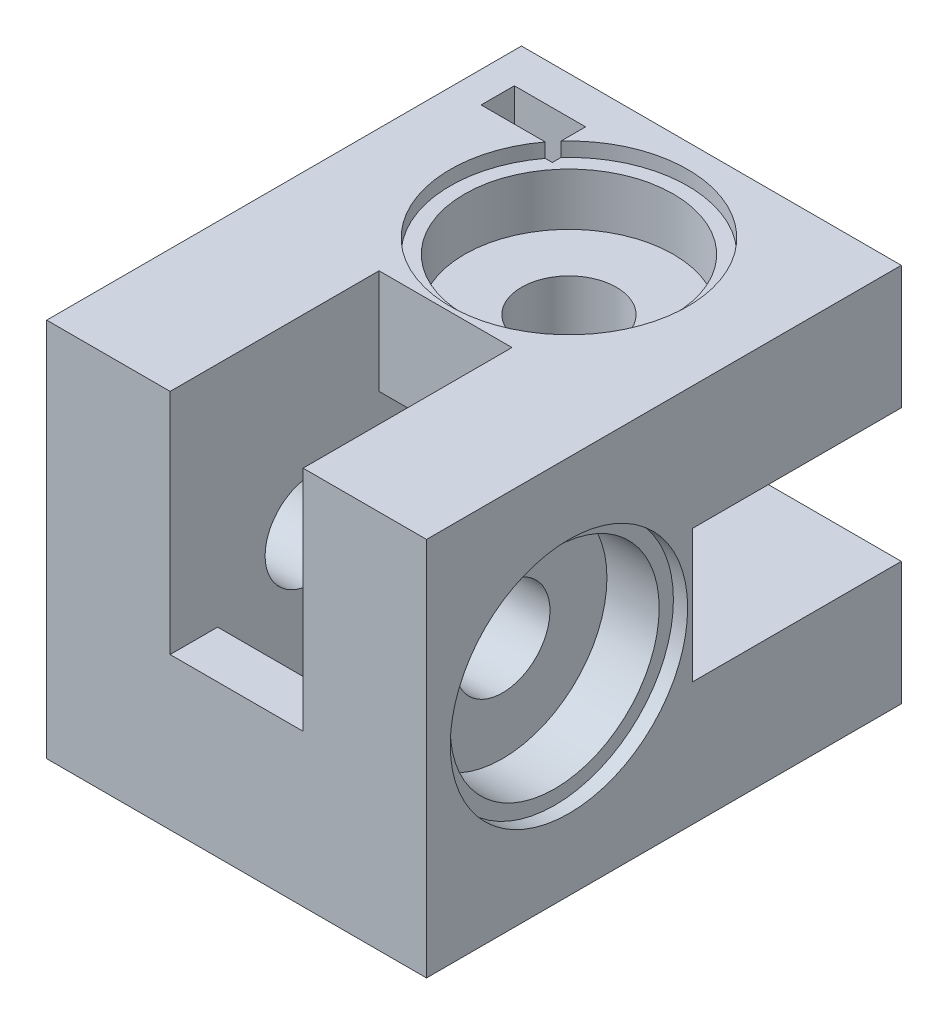
from build123d import *

# Parameters (mm, degrees)
ESQUISSE1_W              = 40
ESQUISSE1_H              = 40
BOSS_EXTRU_1_DEPTH       = 50
ESQUISSE2_R              = 5
ENL_V_MAT_EXTRU_1_DEPTH  = 41
ESQUISSE3_R              = 5
ENL_V_MAT_EXTRU_2_DEPTH  = 41
ESQUISSE4_W              = 20
ESQUISSE4_H              = 14
ENL_V_MAT_EXTRU_3_DEPTH  = 29
ESQUISSE5_W              = 14
ESQUISSE5_H              = 20
ENL_V_MAT_EXTRU_4_DEPTH  = 29
ESQUISSE6_W              = 22
ESQUISSE6_H              = 14
ENL_V_MAT_EXTRU_5_DEPTH  = 24
ESQUISSE7_W              = 14
ESQUISSE7_H              = 22
ENL_V_MAT_EXTRU_6_DEPTH  = 24
ESQUISSE8_R              = 11
ENL_V_MAT_EXTRU_7_DEPTH  = 7
ESQUISSE9_R              = 12.5
ENL_V_MAT_EXTRU_8_DEPTH  = 1.5
ESQUISSE10_R             = 11
ENL_V_MAT_EXTRU_9_DEPTH  = 7
ESQUISSE11_R             = 12.5
ENL_V_MAT_EXTRU_10_DEPTH = 1.5
ESQUISSE13_R             = 2.2
ENL_V_MAT_EXTRU_11_DEPTH = 10
ESQUISSE15_W             = 7.5
ESQUISSE15_H             = 3.5
ENL_V_MAT_EXTRU_13_DEPTH = 12
ESQUISSE16_W             = 7.5
ESQUISSE16_H             = 3.5
ENL_V_MAT_EXTRU_14_DEPTH = 12


with BuildPart() as part:
    # Esquisse1 → Boss.-Extru.1 (new body)
    with BuildSketch(Plane.XY):
        with Locations((-20, 20)):
            Rectangle(ESQUISSE1_W, ESQUISSE1_H)
    extrude(amount=BOSS_EXTRU_1_DEPTH)

    # Esquisse2 → Enlèv. mat.-Extru.1 (cut, through all)
    with BuildSketch(Plane(origin=(0, 40, 0), x_dir=(1, 0, 0), z_dir=(0, 1, 0))):
        with Locations(Location((-20, -15, 0), (0, 0, 270))):  # turned: the seam where the file's is
            Circle(ESQUISSE2_R)
    extrude(amount=-ENL_V_MAT_EXTRU_1_DEPTH, mode=Mode.SUBTRACT)

    # Esquisse3 → Enlèv. mat.-Extru.2 (cut, through all)
    with BuildSketch(Plane.ZY.offset(40)):
        with Locations((35, 20)):
            Circle(ESQUISSE3_R)
    extrude(amount=-ENL_V_MAT_EXTRU_2_DEPTH, mode=Mode.SUBTRACT)

    # Esquisse4 → Enlèv. mat.-Extru.3 (cut)
    with BuildSketch(Plane.ZY.offset(40)):
        with Locations((15, 20)):
            Rectangle(ESQUISSE4_W, ESQUISSE4_H)
    extrude(amount=-ENL_V_MAT_EXTRU_3_DEPTH, mode=Mode.SUBTRACT)

    # Esquisse5 → Enlèv. mat.-Extru.4 (cut)
    with BuildSketch(Plane.XZ):
        with Locations((-20, 35)):
            Rectangle(ESQUISSE5_W, ESQUISSE5_H)
    extrude(amount=-ENL_V_MAT_EXTRU_4_DEPTH, mode=Mode.SUBTRACT)

    # Esquisse6 → Enlèv. mat.-Extru.5 (cut)
    with BuildSketch(Plane(origin=(0, 0, 0), x_dir=(0, 0, -1), z_dir=(1, 0, 0))):
        with Locations((-11, 20)):
            Rectangle(ESQUISSE6_W, ESQUISSE6_H)
    extrude(amount=-ENL_V_MAT_EXTRU_5_DEPTH, mode=Mode.SUBTRACT)

    # Esquisse7 → Enlèv. mat.-Extru.6 (cut)
    with BuildSketch(Plane(origin=(0, 40, 0), x_dir=(1, 0, 0), z_dir=(0, 1, 0))):
        with Locations((-20, -39)):
            Rectangle(ESQUISSE7_W, ESQUISSE7_H)
    extrude(amount=-ENL_V_MAT_EXTRU_6_DEPTH, mode=Mode.SUBTRACT)

    # Esquisse8 → Enlèv. mat.-Extru.7 (cut)
    with BuildSketch(Plane(origin=(0, 0, 0), x_dir=(0, 0, -1), z_dir=(1, 0, 0))):
        with Locations(Location((-35, 20, 0), (0, 0, 90))):  # turned: the seam where the file's is
            Circle(ESQUISSE8_R)
    extrude(amount=-ENL_V_MAT_EXTRU_7_DEPTH, mode=Mode.SUBTRACT)

    # Esquisse9 → Enlèv. mat.-Extru.8 (cut)
    with BuildSketch(Plane(origin=(0, 0, 0), x_dir=(0, 0, -1), z_dir=(1, 0, 0))):
        with Locations(Location((-35, 20, 0), (0, 0, 90))):  # turned: the seam where the file's is
            Circle(ESQUISSE9_R)
    extrude(amount=-ENL_V_MAT_EXTRU_8_DEPTH, mode=Mode.SUBTRACT)

    # Esquisse10 → Enlèv. mat.-Extru.9 (cut)
    with BuildSketch(Plane(origin=(0, 40, 0), x_dir=(1, 0, 0), z_dir=(0, 1, 0))):
        with Locations(Location((-20, -15, 0), (0, 0, 270))):  # turned: the seam where the file's is
            Circle(ESQUISSE10_R)
    extrude(amount=-ENL_V_MAT_EXTRU_9_DEPTH, mode=Mode.SUBTRACT)

    # Esquisse11 → Enlèv. mat.-Extru.10 (cut)
    with BuildSketch(Plane(origin=(0, 40, 0), x_dir=(1, 0, 0), z_dir=(0, 1, 0))):
        with Locations(Location((-20, -15, 0), (0, 0, 270))):  # turned: the seam where the file's is
            Circle(ESQUISSE11_R)
    extrude(amount=-ENL_V_MAT_EXTRU_10_DEPTH, mode=Mode.SUBTRACT)

    # Esquisse13 → Enlèv. mat.-Extru.11 (cut)
    with BuildSketch(Plane(origin=(0, 0, 0), x_dir=(-1, 0, 0), z_dir=(0, 0, -1))):
        with Locations((33, 32)):
            Circle(ESQUISSE13_R)
        with Locations((8, 7)):
            Circle(ESQUISSE13_R)
    extrude(amount=-ENL_V_MAT_EXTRU_11_DEPTH, mode=Mode.SUBTRACT)

    # Esquisse15 → Enlèv. mat.-Extru.13 (cut)
    with BuildSketch(Plane(origin=(0, 40, 0), x_dir=(1, 0, 0), z_dir=(0, 1, 0))):
        with Locations((-33, -5.75)):
            Rectangle(ESQUISSE15_W, ESQUISSE15_H)
    extrude(amount=-ENL_V_MAT_EXTRU_13_DEPTH, mode=Mode.SUBTRACT)

    # Esquisse16 → Enlèv. mat.-Extru.14 (cut)
    with BuildSketch(Plane.XZ):
        with Locations((-8, 5.75)):
            Rectangle(ESQUISSE16_W, ESQUISSE16_H)
    extrude(amount=-ENL_V_MAT_EXTRU_14_DEPTH, mode=Mode.SUBTRACT)


solid = part.part
